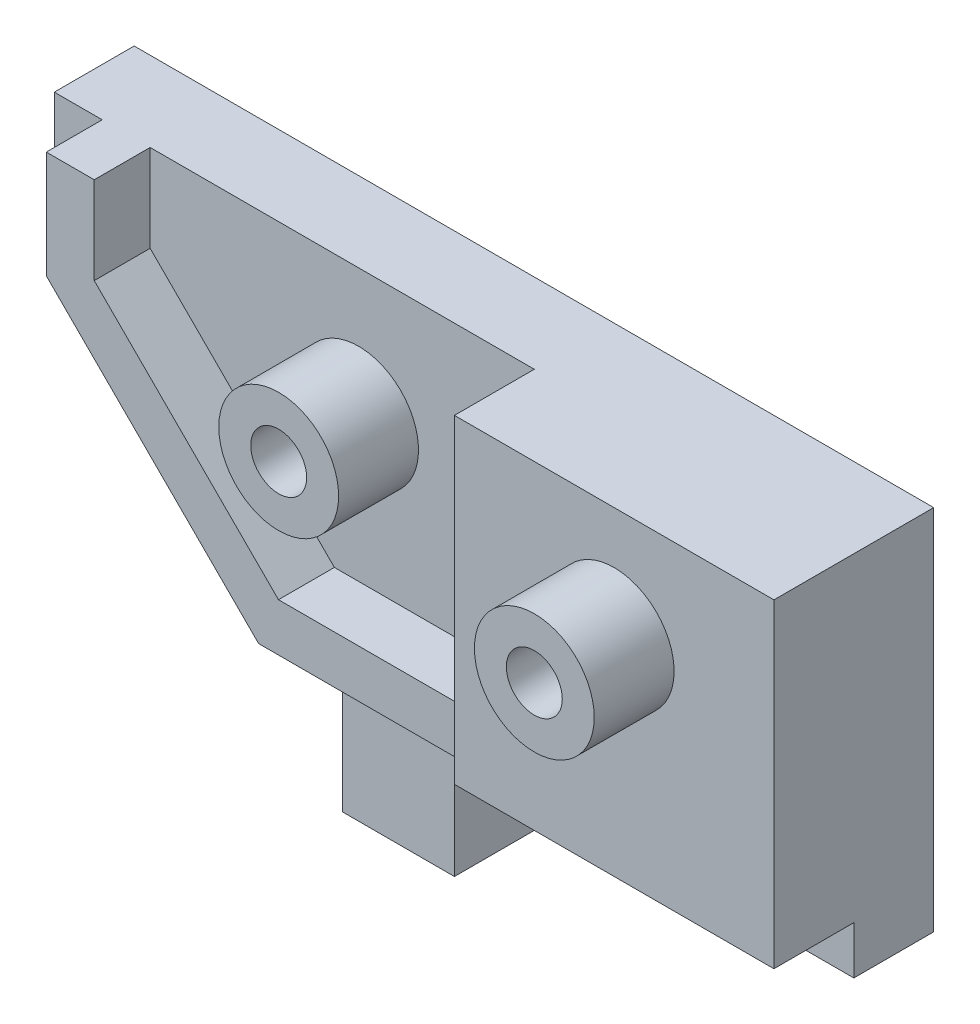
from build123d import *

# Parameters (mm, degrees)
BOSS_EXTRUDE1_DEPTH = 23
SKETCH2_R           = 1.75
CUT_EXTRUDE1_DEPTH  = 10
SKETCH4_W           = 7
SKETCH4_H           = 5
BOSS_EXTRUDE2_DEPTH = 7
SKETCH6_R           = 3.75
SKETCH6_R_2         = 1.75
BOSS_EXTRUDE3_DEPTH = 5
SKETCH7_R           = 3.75
SKETCH7_R_2         = 1.75
BOSS_EXTRUDE4_DEPTH = 5
BOSS_EXTRUDE5_DEPTH = 5
BOSS_EXTRUDE6_DEPTH = 3.5
SKETCH3_R           = 1.75
CUT_EXTRUDE2_DEPTH  = 10
SKETCH12_W          = 5
SKETCH12_H          = 3
CUT_EXTRUDE3_DEPTH  = 20


with BuildPart() as part:
    # Sketch1 → Boss-Extrude1 (new body)
    with BuildSketch(Plane(origin=(0, 0, 0), x_dir=(1, 0, 0), z_dir=(0, 1, 0))):
        Polygon((18, 0), (22, 0), (35, 0), (35, -5), (35, -10), (15, -10), (15, -5), (0, -5), (0, 0), align=None)
    extrude(amount=BOSS_EXTRUDE1_DEPTH)

    # Sketch2 → Cut-Extrude1 (cut)
    with BuildSketch(Plane.XY.offset(10)):
        with Locations((4, 15)):
            Circle(SKETCH2_R)
        with Locations((25, 16)):
            Circle(SKETCH2_R)
    extrude(amount=-CUT_EXTRUDE1_DEPTH, mode=Mode.SUBTRACT)

    # Sketch4 → Boss-Extrude2 (add)
    with BuildSketch(Plane.XZ):
        with Locations((6.5, 2.5)):
            Rectangle(SKETCH4_W, SKETCH4_H)
    extrude(amount=BOSS_EXTRUDE2_DEPTH)

    # Sketch6 → Boss-Extrude3 (add)
    with BuildSketch(Plane.XY.offset(5)):
        with Locations((4, 15)):
            Circle(SKETCH6_R)
        with Locations((4, 15)):
            Circle(SKETCH6_R_2, mode=Mode.SUBTRACT)
    extrude(amount=BOSS_EXTRUDE3_DEPTH)

    # Sketch7 → Boss-Extrude4 (add)
    with BuildSketch(Plane.XY.offset(10)):
        with Locations((25, 16)):
            Circle(SKETCH7_R)
        with Locations((25, 16)):
            Circle(SKETCH7_R_2, mode=Mode.SUBTRACT)
    extrude(amount=BOSS_EXTRUDE4_DEPTH)

    # Sketch10 → Boss-Extrude5 (add)
    with BuildSketch(Plane.XY.offset(5)):
        Polygon((0, 23), (-15.047232304, 23), (-15.047232304, 15.047232304), (0, 0), align=None)
    extrude(amount=-BOSS_EXTRUDE5_DEPTH)

    # Sketch11 → Boss-Extrude6 (add)
    with BuildSketch(Plane.XY.offset(5)):
        Polygon((-12.047232304, 23), (-12.047232304, 16.289872991), (1.242640687, 3), (15, 3), (15, 6), (2.485281374, 6), (-9.047232304, 17.532513678), (-9.047232304, 23), align=None)
    extrude(amount=BOSS_EXTRUDE6_DEPTH)

    # Sketch3 → Cut-Extrude2 (cut)
    with BuildSketch(Plane.XZ):
        with Locations((25, 2.5)):
            Circle(SKETCH3_R)
    extrude(amount=-CUT_EXTRUDE2_DEPTH, mode=Mode.SUBTRACT)

    # Sketch12 → Cut-Extrude3 (cut)
    with BuildSketch(Plane.ZY.offset(-15)):
        with Locations((7.5, 1.5)):
            Rectangle(SKETCH12_W, SKETCH12_H)
    extrude(amount=-CUT_EXTRUDE3_DEPTH, mode=Mode.SUBTRACT)


solid = part.part
